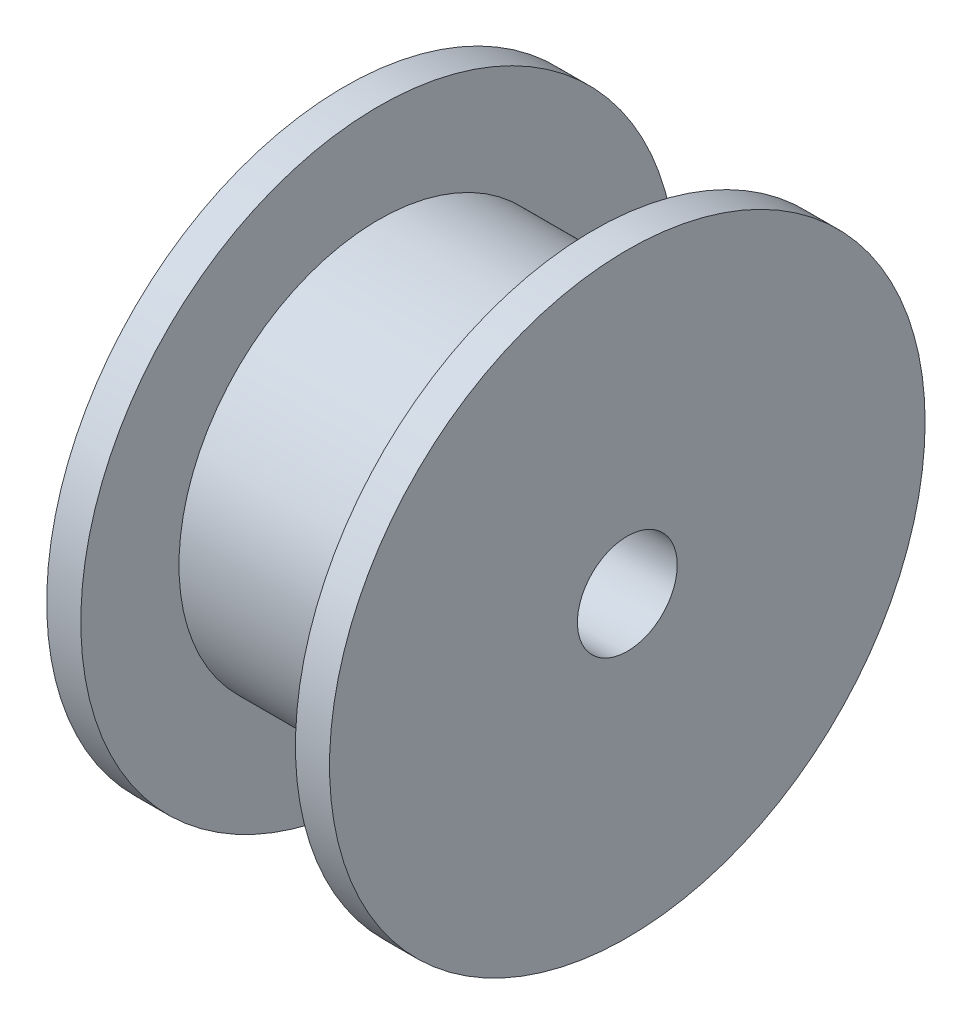
from build123d import *


with BuildPart() as part:
    # Sketch1 → Revolve1 (revolve)
    with BuildSketch(Plane.XY):
        Polygon((8.268847172, 8.95), (8.268847172, 1.5), (16.768847172, 1.5), (16.768847172, 8.95), (15.743847172, 8.95), (15.743847172, 6), (9.293847172, 6), (9.293847172, 8.95), align=None)
    revolve(axis=Axis((0, 0, 0), (-1, 0, 0)))


solid = part.part
